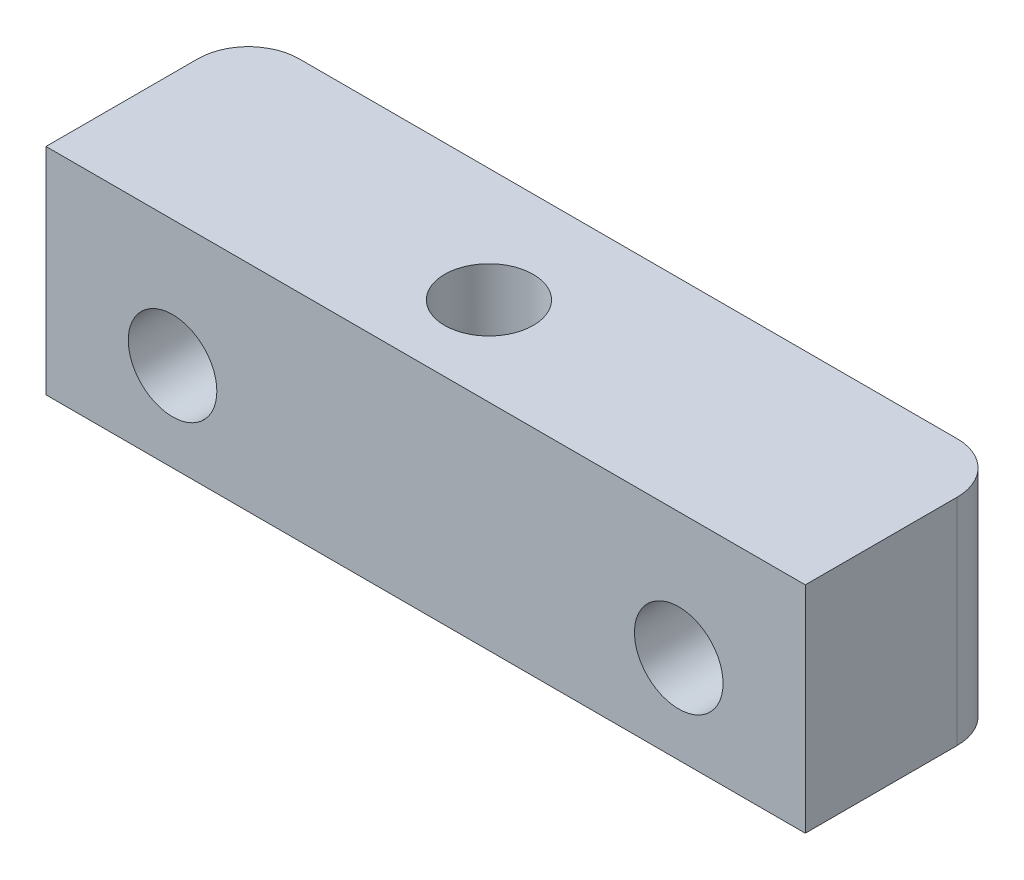
from build123d import *

# Parameters (mm, degrees)
SKETCH1_W           = 30
SKETCH1_H           = 8
SKETCH1_R           = 1.75
BOSS_EXTRUDE1_DEPTH = 2
SKETCH2_R           = 1.75
BOSS_EXTRUDE2_DEPTH = 8
FILLET1_R           = 2
SKETCH3_R           = 1.75
CUT_EXTRUDE1_DEPTH  = 7.5
CUT_EXTRUDE2_DEPTH  = 3


with BuildPart() as part:
    # Sketch1 → Boss-Extrude1 (new body)
    with BuildSketch(Plane(origin=(0, 0, 0), x_dir=(1, 0, 0), z_dir=(0, 1, 0))):
        Rectangle(SKETCH1_W, SKETCH1_H)
        with Locations((-1, -0.5)):
            Circle(SKETCH1_R, mode=Mode.SUBTRACT)
    extrude(amount=BOSS_EXTRUDE1_DEPTH)

    # Sketch2 → Boss-Extrude2 (add)
    with BuildSketch(Plane.XY.offset(4)):
        Polygon((-15, 0), (-5, 0), (5, 0), (15, 0), (15, -6.5), (-15, -6.5), align=None)
        with Locations((-10, -3)):
            Circle(SKETCH2_R, mode=Mode.SUBTRACT)
        with Locations((10, -3)):
            Circle(SKETCH2_R, mode=Mode.SUBTRACT)
    extrude(amount=-BOSS_EXTRUDE2_DEPTH)

    # Fillet1
    fillet1_edges = [part.edges().sort_by_distance(p)[0] for p in [
        (-15, -2.25, -4),
        (15, -2.25, -4),
    ]]
    fillet(fillet1_edges, radius=FILLET1_R)

    # Sketch3 → Cut-Extrude1 (cut, through all)
    with BuildSketch(Plane(origin=(0, 0, 0), x_dir=(1, 0, 0), z_dir=(0, 1, 0))):
        with Locations((-1, -0.5)):
            Circle(SKETCH3_R)
    extrude(amount=-CUT_EXTRUDE1_DEPTH, mode=Mode.SUBTRACT)

    # Sketch4 → Cut-Extrude2 (cut)
    with BuildSketch(Plane.XZ.offset(6.5)):
        Polygon((2.464101615, 0.5), (0.732050808, 3.5), (-2.732050808, 3.5), (-4.464101615, 0.5), (-2.732050808, -2.5), (0.732050808, -2.5), align=None)
    extrude(amount=-CUT_EXTRUDE2_DEPTH, mode=Mode.SUBTRACT)


solid = part.part
